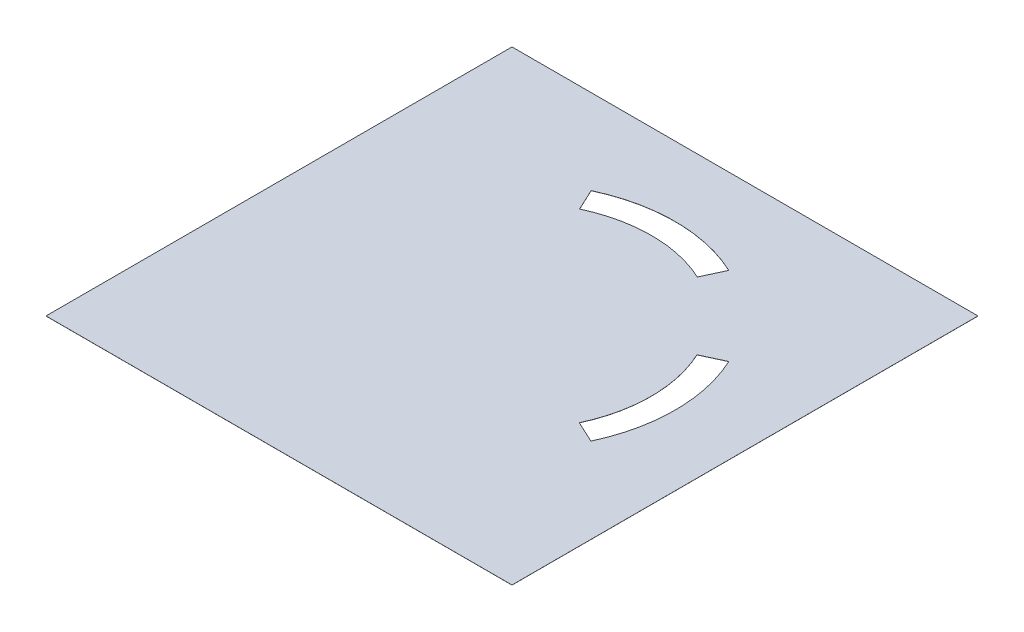
from build123d import *

# Parameters (mm, degrees)
SKETCH1_W           = 107.07
SKETCH1_H           = 107.07
BOSS_EXTRUDE1_DEPTH = 0.02


with BuildPart() as part:
    # Sketch1 → Boss-Extrude1 (new body)
    with BuildSketch(Plane(origin=(0, 0, 0), x_dir=(1, 0, 0), z_dir=(0, 1, 0))):
        with Locations((53.535, 53.535)):
            Rectangle(SKETCH1_W, SKETCH1_H)
        with BuildLine():
            Line((40.02098899, 82.576362505), (37.69526755, 87.563888229))
            ThreePointArc((37.69526755, 87.563888229), (53.541760789, 91.075404612), (69.37473245, 87.503415858))
            Line((69.37473245, 87.503415858), (67.077209739, 82.576362505))
            ThreePointArc((67.077209739, 82.576362505), (53.549099365, 85.57547237), (40.02098899, 82.576362505))
        make_face(mode=Mode.SUBTRACT)
        with BuildLine():
            Line((82.518723029, 67.05033201), (87.503415858, 69.37473245))
            ThreePointArc((87.503415858, 69.37473245), (91.015, 53.535), (87.503415858, 37.69526755))
            Line((87.503415858, 37.69526755), (82.518723029, 40.01966799))
            ThreePointArc((82.518723029, 40.01966799), (85.515, 53.535), (82.518723029, 67.05033201))
        make_face(mode=Mode.SUBTRACT)
    extrude(amount=BOSS_EXTRUDE1_DEPTH)


solid = part.part
